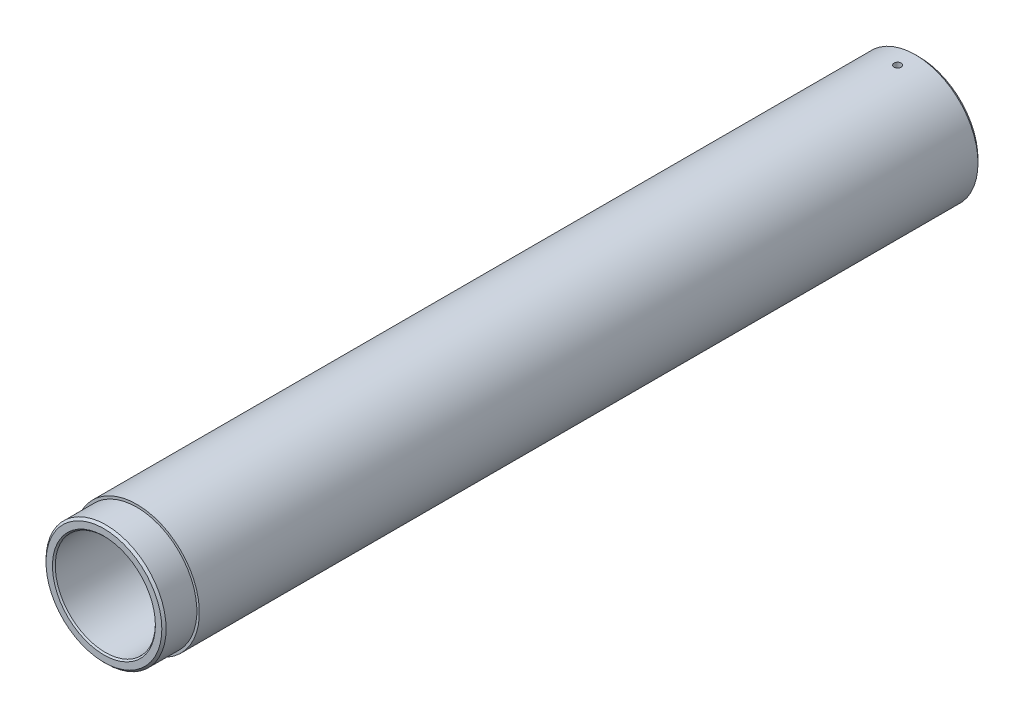
from build123d import *

# Parameters (mm, degrees)
SKETCH1_R           = 87.5
SKETCH1_R_2         = 70
BOSS_EXTRUDE1_DEPTH = 570
CHAMFER1_SIZE       = 5
SKETCH3_W           = 46
SKETCH3_H           = 23.271648671
CHAMFER2_SIZE       = 3
CHAMFER3_SIZE       = 2
SKETCH4_R           = 5
CUT_EXTRUDE1_DEPTH  = 102


with BuildPart() as part:
    # Sketch1 → Boss-Extrude1 (new body, symmetric)
    with BuildSketch(Plane.XY):
        Circle(SKETCH1_R)
        Circle(SKETCH1_R_2, mode=Mode.SUBTRACT)
    extrude(amount=BOSS_EXTRUDE1_DEPTH, both=True)

    # Chamfer1
    chamfer1_edges = [part.edges().sort_by_distance(p)[0] for p in [
        (-87.5, 0, -570),
    ]]
    chamfer(chamfer1_edges, length=CHAMFER1_SIZE)

    # Sketch3 → Cut-Revolve1 (revolve, cut)
    with BuildSketch(Plane(origin=(0, 0, 0), x_dir=(0, 0, -1), z_dir=(1, 0, 0))):
        with Locations((-547, 95.635824336)):
            Rectangle(SKETCH3_W, SKETCH3_H)
    revolve(axis=Axis((0, 0, 0), (0, 0, 1)), mode=Mode.SUBTRACT)

    # Chamfer2
    chamfer2_edges = [part.edges().sort_by_distance(p)[0] for p in [
        (0, -84, 570),
    ]]
    chamfer(chamfer2_edges, length=CHAMFER2_SIZE)

    # Chamfer3
    chamfer3_edges = [part.edges().sort_by_distance(p)[0] for p in [
        (-70, 0, 570),
    ]]
    chamfer(chamfer3_edges, length=CHAMFER3_SIZE)

    # Sketch4 → Cut-Extrude1 (cut)
    with BuildSketch(Plane(origin=(0, 0, 0), x_dir=(1, 0, 0), z_dir=(0, 1, 0))):
        with Locations((0, 540)):
            Circle(SKETCH4_R)
    extrude(amount=CUT_EXTRUDE1_DEPTH, mode=Mode.SUBTRACT)


solid = part.part
